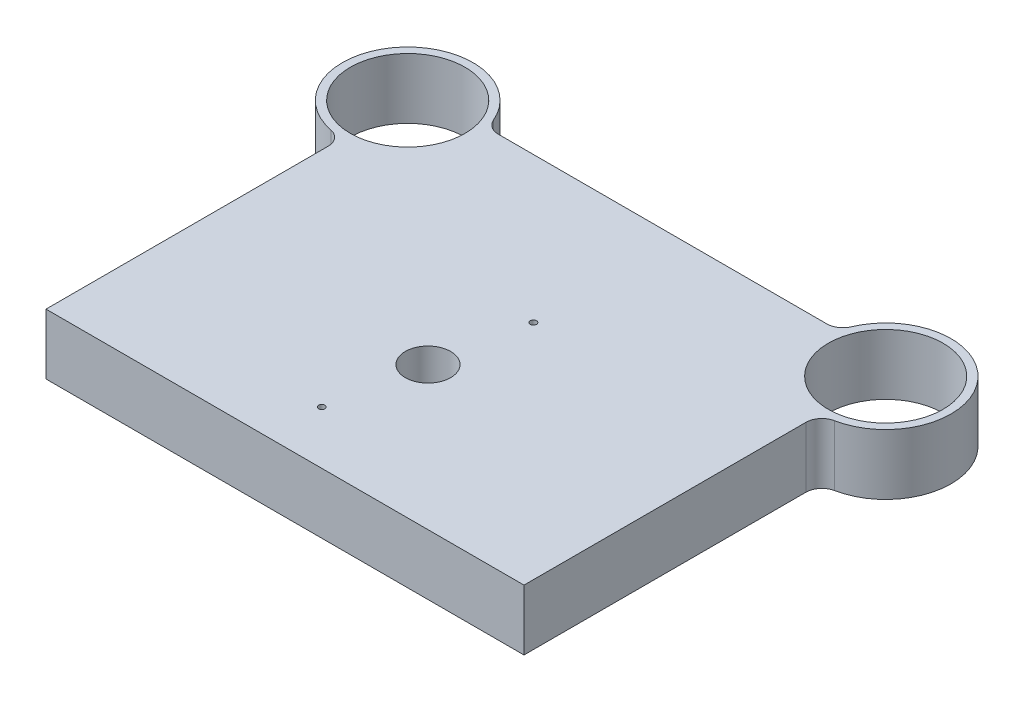
from build123d import *

# Parameters (mm, degrees)
SKETCH1_R                  = 36
BOSS_EXTRUDE1_DEPTH        = 38
FILLET1_R                  = 10
SKETCH2_R                  = 1.99
CUT_EXTRUDE1_DEPTH         = 39
M20X1_5_TAPPED_HOLE1_D     = 18.5
M20X1_5_TAPPED_HOLE1_DEPTH = 30
M20X1_5_TAPPED_HOLE1_TIP   = 5.557960726
M30X1_5_TAPPED_HOLE1_D     = 28.5
M30X1_5_TAPPED_HOLE1_DEPTH = 30
M30X1_5_TAPPED_HOLE1_TIP   = 8.562263821


with BuildPart() as part:
    # Sketch1 → Boss-Extrude1 (new body)
    with BuildSketch(Plane(origin=(0, 0, 0), x_dir=(1, 0, 0), z_dir=(0, 1, 0))):
        with BuildLine():
            Line((150, 0), (-150, 0))
            Line((-150, 0), (-150, 186))
            ThreePointArc((-150, 186), (-182.334192428, 252.209125332), (-110.238209296, 237))
            Line((-110.238209296, 237), (110.238209296, 237))
            ThreePointArc((110.238209296, 237), (182.334192428, 252.209125332), (150, 186))
            Line((150, 186), (150, 0))
        make_face()
        with Locations((-150, 227)):
            Circle(SKETCH1_R, mode=Mode.SUBTRACT)
        with Locations((150, 227)):
            Circle(SKETCH1_R, mode=Mode.SUBTRACT)
    extrude(amount=BOSS_EXTRUDE1_DEPTH)

    # Fillet1
    fillet1_edges = [part.edges().sort_by_distance(p)[0] for p in [
        (-150, 19, -186),
        (-110.238209296, 19, -237),
        (110.238209296, 19, -237),
        (150, 19, -186),
    ]]
    fillet(fillet1_edges, radius=FILLET1_R)

    # Sketch2 → Cut-Extrude1 (cut, through all)
    with BuildSketch(Plane(origin=(0, 38, 0), x_dir=(1, 0, 0), z_dir=(0, 1, 0))):
        with Locations((-10.25, 33.3)):
            Circle(SKETCH2_R)
        with Locations((10.25, 145.68)):
            Circle(SKETCH2_R)
    extrude(amount=-CUT_EXTRUDE1_DEPTH, mode=Mode.SUBTRACT)

    # M20x1.5 Tapped Hole1
    with Locations(Plane(origin=(0, 0, 0), x_dir=(-1, 0, 0), z_dir=(0, -1, 0))):
        with Locations((42.25, 145.68), (-42.25, 145.68), (42.25, 33.3), (-42.25, 33.3)):
            Hole(M20X1_5_TAPPED_HOLE1_D / 2, depth=M20X1_5_TAPPED_HOLE1_DEPTH)
            with Locations((0, 0, -(M20X1_5_TAPPED_HOLE1_DEPTH + M20X1_5_TAPPED_HOLE1_TIP / 2))):  # 118° drill point
                Cone(0, M20X1_5_TAPPED_HOLE1_D / 2, M20X1_5_TAPPED_HOLE1_TIP, mode=Mode.SUBTRACT)

    # M30x1.5 Tapped Hole1
    with Locations(Plane(origin=(0, 38, 0), x_dir=(1, 0, 0), z_dir=(0, 1, 0))):
        with Locations((0, 89.74)):
            Hole(M30X1_5_TAPPED_HOLE1_D / 2, depth=M30X1_5_TAPPED_HOLE1_DEPTH)
            with Locations((0, 0, -(M30X1_5_TAPPED_HOLE1_DEPTH + M30X1_5_TAPPED_HOLE1_TIP / 2))):  # 118° drill point
                Cone(0, M30X1_5_TAPPED_HOLE1_D / 2, M30X1_5_TAPPED_HOLE1_TIP, mode=Mode.SUBTRACT)


solid = part.part
